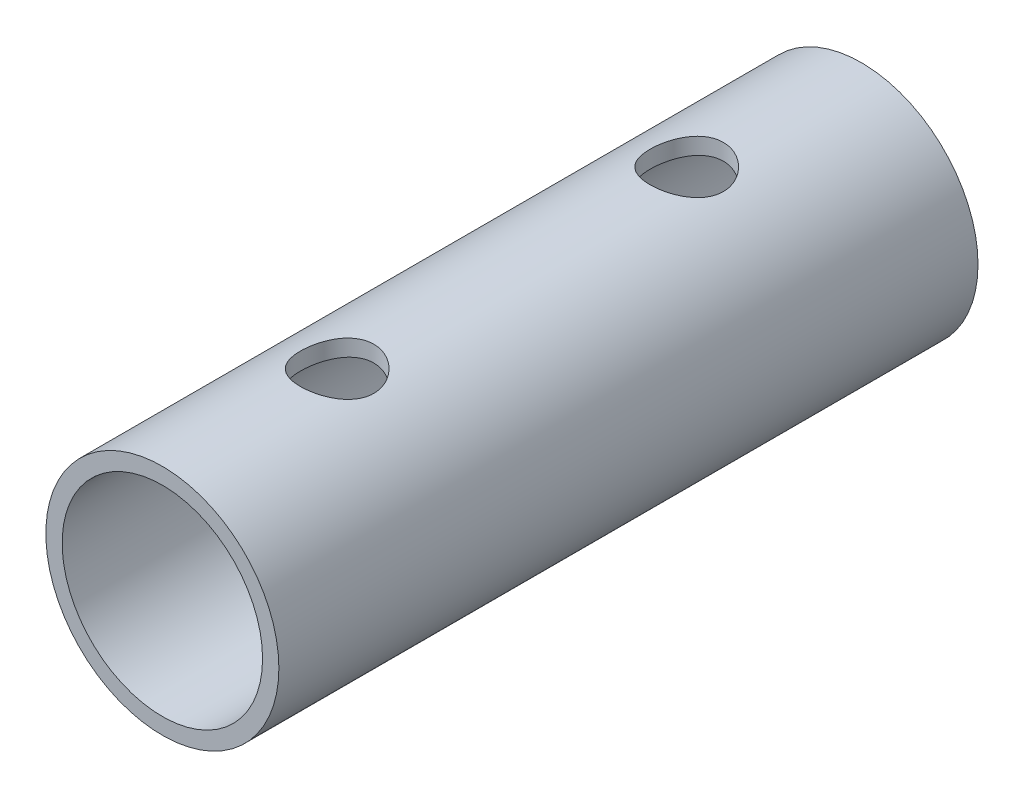
from build123d import *

# Parameters (mm, degrees)
SKETCH1_R               = 6.35
SKETCH1_R_2             = 5.461
EXTRUDE1_DEPTH          = 38.1
SKETCH2_R               = 2
CUT_EXTRUDE1_DEPTH      = 38.1
CUT_EXTRUDE1_DEPTH_BACK = 38.1


with BuildPart() as part:
    # Sketch1 → Extrude1 (new body)
    with BuildSketch(Plane.XY):
        Circle(SKETCH1_R)
        Circle(SKETCH1_R_2, mode=Mode.SUBTRACT)
    extrude(amount=EXTRUDE1_DEPTH)

    # Sketch2 → Cut-Extrude1 (cut, two sides)
    with BuildSketch(Plane(origin=(0, 0, 0), x_dir=(1, 0, 0), z_dir=(0, 1, 0))) as cut_extrude1_sk:
        with Locations(Location((0, -9.525, 0), (0, 0, 270))):  # turned: the seam where the file's is
            Circle(SKETCH2_R)
        with Locations(Location((0, -28.575, 0), (0, 0, 270))):  # turned: the seam where the file's is
            Circle(SKETCH2_R)
    extrude(amount=CUT_EXTRUDE1_DEPTH, mode=Mode.SUBTRACT)
    extrude(cut_extrude1_sk.sketch, amount=-CUT_EXTRUDE1_DEPTH_BACK, mode=Mode.SUBTRACT)


solid = part.part
